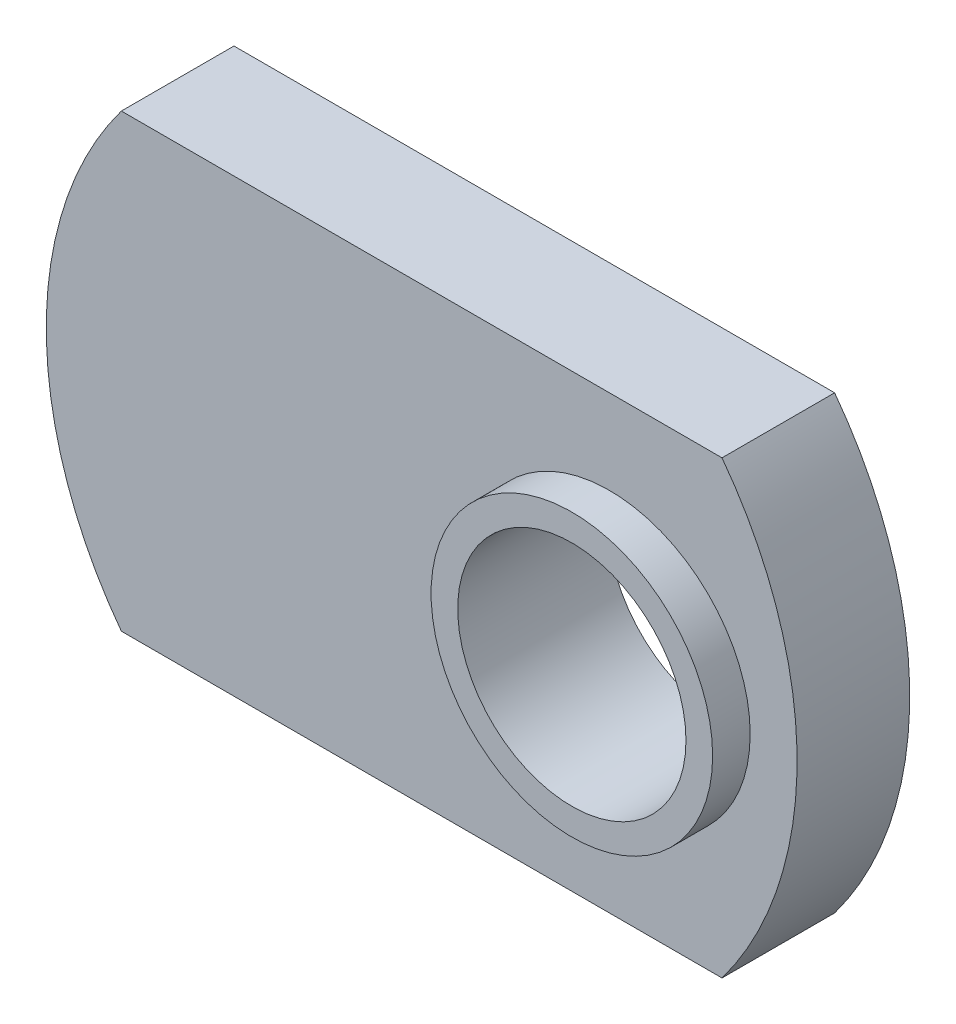
from build123d import *

# Parameters (mm, degrees)
SKETCH1_R      = 2.413
EXTRUDE1_DEPTH = 2.38125
SKETCH2_R      = 2.9765625
SKETCH2_R_2    = 2.413
EXTRUDE2_DEPTH = 0.79375


with BuildPart() as part:
    # Sketch1 → Extrude1 (new body)
    with BuildSketch(Plane.XY):
        with BuildLine():
            Line((-6.35, 4.7625), (6.35, 4.7625))
            ThreePointArc((6.35, 4.7625), (7.9375, 0), (6.35, -4.7625))
            Line((6.35, -4.7625), (-6.35, -4.7625))
            ThreePointArc((-6.35, -4.7625), (-7.9375, 0), (-6.35, 4.7625))
        make_face()
        with Locations((3.96875, 0)):
            Circle(SKETCH1_R, mode=Mode.SUBTRACT)
    extrude(amount=EXTRUDE1_DEPTH)

    # Sketch2 → Extrude2 (add)
    with BuildSketch(Plane.XY.offset(2.38125)):
        with Locations((3.96875, 0)):
            Circle(SKETCH2_R)
        with Locations((3.96875, 0)):
            Circle(SKETCH2_R_2, mode=Mode.SUBTRACT)
    extrude(amount=EXTRUDE2_DEPTH)


solid = part.part
